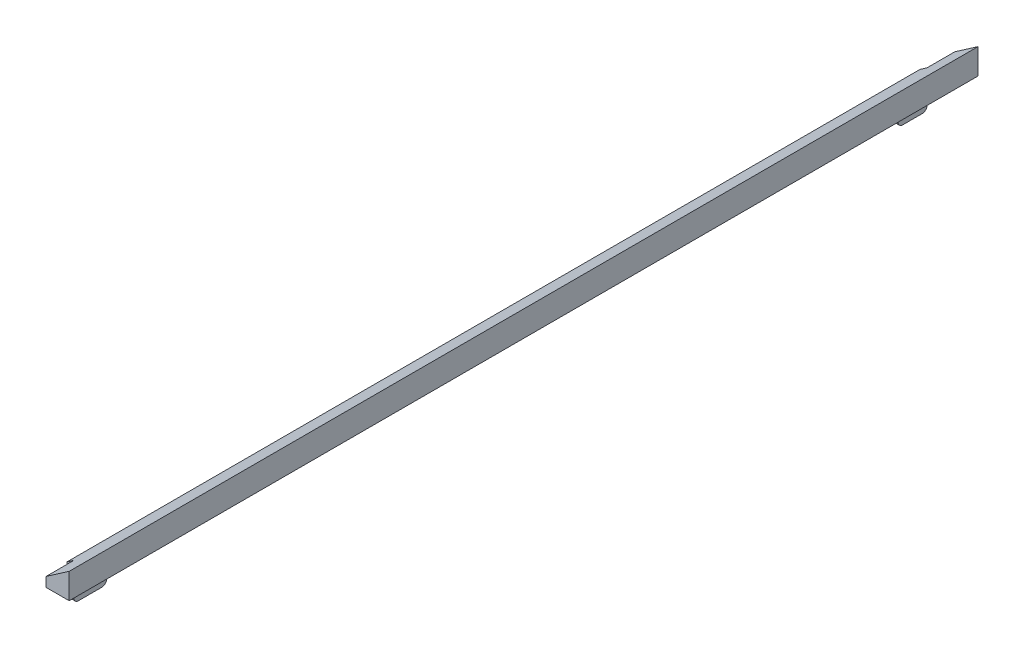
from build123d import *

# Parameters (mm, degrees)
SKETCH1_W           = 6.5
SKETCH1_H           = 5.5
BOSS_EXTRUDE1_DEPTH = 184
CUT_EXTRUDE2_DEPTH  = 185
SKETCH3_W           = 1.5
SKETCH3_H           = 6.243718407
SKETCH3_H_2         = 7.062553001
BOSS_EXTRUDE2_DEPTH = 6
SKETCH4_R           = 1.4
CUT_EXTRUDE3_DEPTH  = 7.5
FILLET1_R           = 1
BOSS_EXTRUDE3_DEPTH = 6
BOSS_EXTRUDE4_DEPTH = 6


with BuildPart() as part:
    # Sketch1 → Boss-Extrude1 (new body)
    with BuildSketch(Plane.XY):
        with Locations((3.25, 2.75)):
            Rectangle(SKETCH1_W, SKETCH1_H)
    extrude(amount=BOSS_EXTRUDE1_DEPTH)

    # Sketch2 → Cut-Extrude2 (cut, through all)
    with BuildSketch(Plane(origin=(0, 0, 0), x_dir=(-1, 0, 0), z_dir=(0, 0, -1))):
        Polygon((0, 1), (-6.5, 5.5), (0, 5.5), align=None)
    extrude(amount=-CUT_EXTRUDE2_DEPTH, mode=Mode.SUBTRACT)

    # Sketch3 → Boss-Extrude2 (add)
    with BuildSketch(Plane.XZ):
        with Locations((0.75, 3.121859204)):
            Rectangle(SKETCH3_W, SKETCH3_H)
        with Locations((0.75, 180.4687235)):
            Rectangle(SKETCH3_W, SKETCH3_H_2)
    extrude(amount=BOSS_EXTRUDE2_DEPTH)

    # Sketch4 → Cut-Extrude3 (cut, through all)
    with BuildSketch(Plane.ZY):
        with Locations((180.937446999, -3)):
            Circle(SKETCH4_R)
    cut_extrude3 = extrude(amount=-CUT_EXTRUDE3_DEPTH, mode=Mode.SUBTRACT)

    # Mirror1: Cut-Extrude3 across plane
    add(cut_extrude3.mirror(Plane.XY.offset(92)), mode=Mode.SUBTRACT)

    # Fillet1
    fillet1_edges = [part.edges().sort_by_distance(p)[0] for p in [
        (0.75, -6, 6.243718407),
        (0.75, -6, 0),
        (0.75, -6, 184),
        (0.75, -6, 176.937446999),
    ]]
    fillet(fillet1_edges, radius=FILLET1_R)

    # Sketch5 → Boss-Extrude3 (add)
    with BuildSketch(Plane(origin=(0, 0, 0), x_dir=(-1, 0, 0), z_dir=(0, 0, -1))):
        Polygon((-6.5, 0), (-6.5, 5.5), (-1.5, 2.038461538), (-1.5, 0), align=None)
    extrude(amount=BOSS_EXTRUDE3_DEPTH)

    # Sketch6 → Boss-Extrude4 (add)
    with BuildSketch(Plane.XY.offset(184)):
        Polygon((6.5, 5.5), (6.5, 0), (1.5, 0), (1.5, 2.038461538), align=None)
    extrude(amount=BOSS_EXTRUDE4_DEPTH)


solid = part.part
